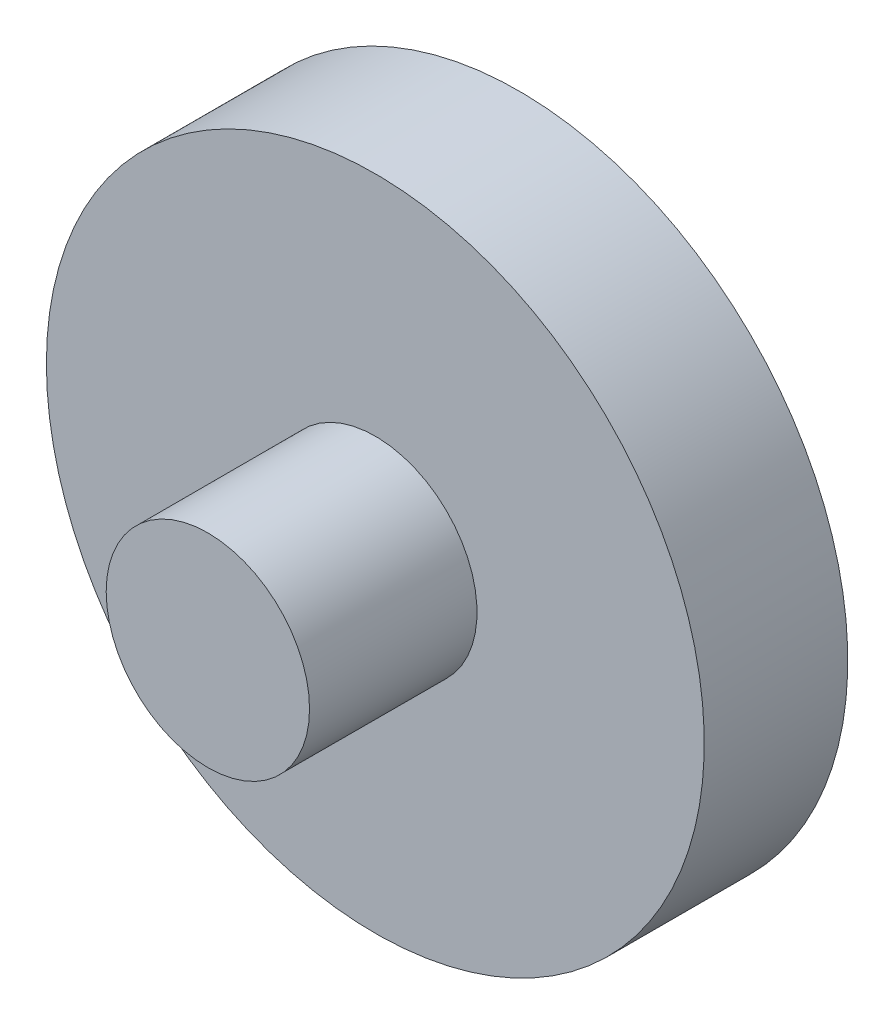
from build123d import *

# Parameters (mm, degrees)
SKETCH1_R           = 8.5
BOSS_EXTRUDE1_DEPTH = 10
SKETCH2_R           = 27.5
BOSS_EXTRUDE2_DEPTH = 6


with BuildPart() as part:
    # Sketch1 → Boss-Extrude1 (new body, symmetric)
    with BuildSketch(Plane.XY):
        Circle(SKETCH1_R)
    extrude(amount=BOSS_EXTRUDE1_DEPTH, both=True)

    # Sketch2 → Boss-Extrude2 (add, symmetric)
    with BuildSketch(Plane(origin=(0, 0, -10), x_dir=(-1, 0, 0), z_dir=(0, 0, -1))):
        Circle(SKETCH2_R)
    extrude(amount=BOSS_EXTRUDE2_DEPTH, both=True)


solid = part.part
